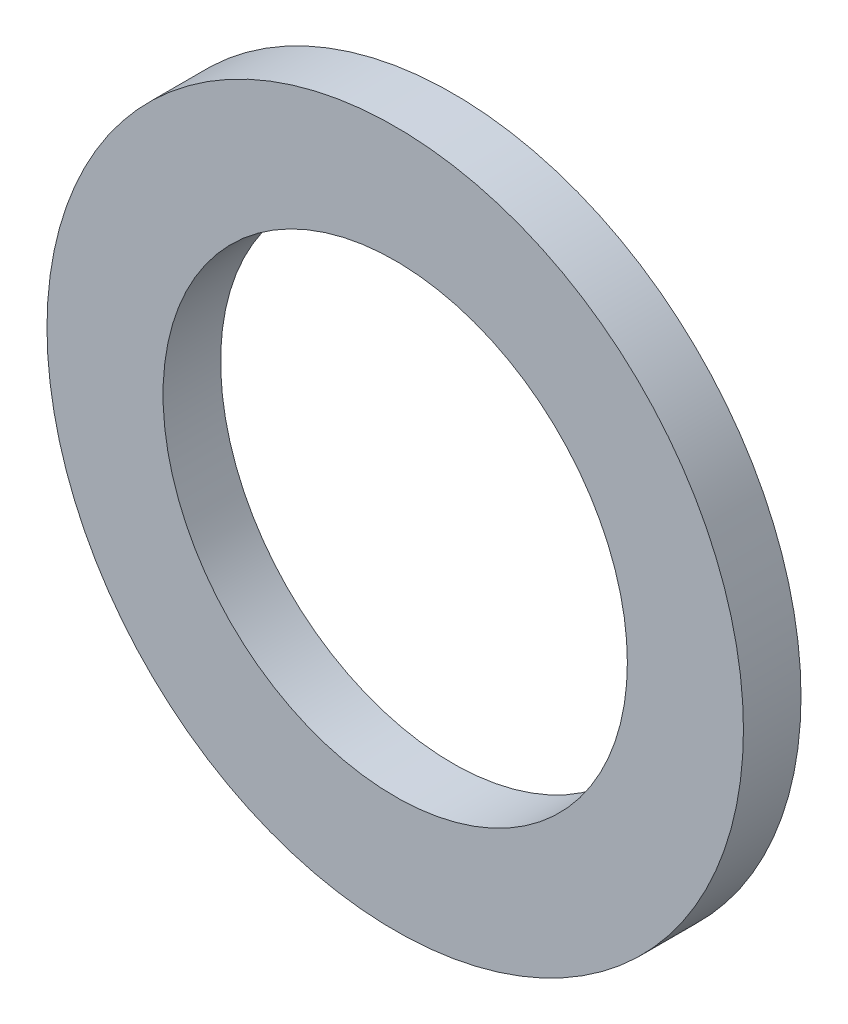
from build123d import *

# Parameters (mm, degrees)
SKETCH1_R           = 4.7625
SKETCH1_R_2         = 3.175
BOSS_EXTRUDE1_DEPTH = 0.7874


with BuildPart() as part:
    # Sketch1 → Boss-Extrude1 (new body)
    with BuildSketch(Plane.XY):
        Circle(SKETCH1_R)
        Circle(SKETCH1_R_2, mode=Mode.SUBTRACT)
    extrude(amount=BOSS_EXTRUDE1_DEPTH)


solid = part.part
